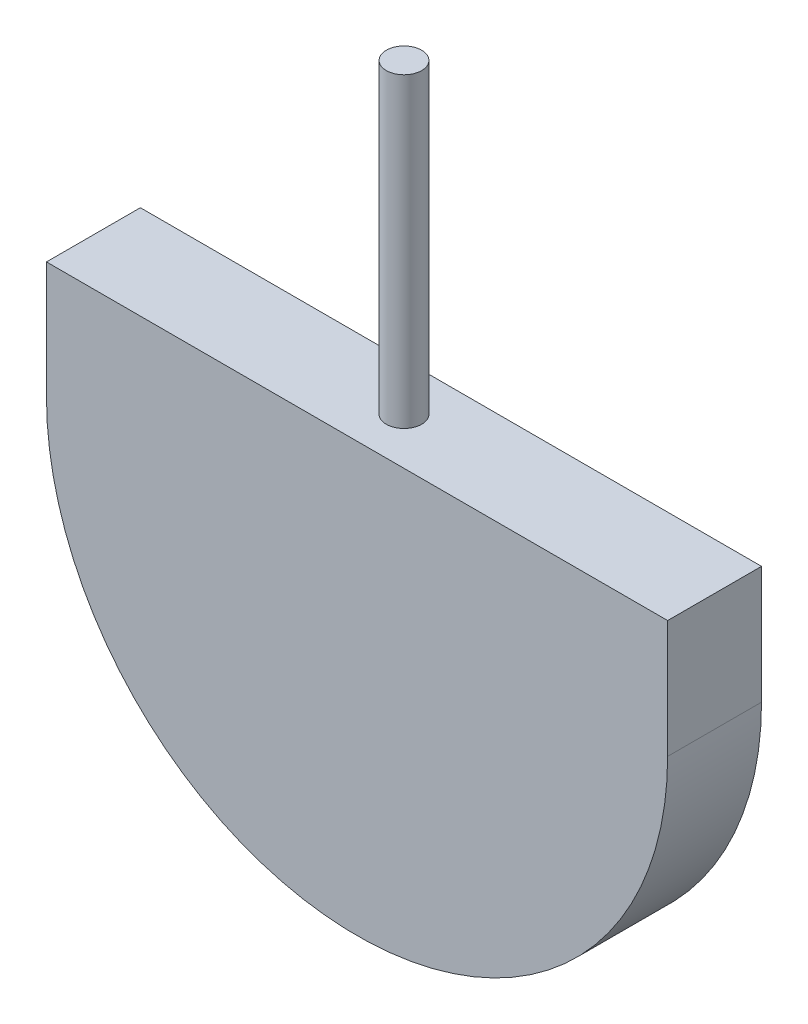
from build123d import *

# Parameters (mm, degrees)
BOSS_EXTRUDE1_DEPTH = 3.99
SKETCH2_R           = 0.75
BOSS_EXTRUDE2_DEPTH = 13.019979


with BuildPart() as part:
    # Sketch1 → Boss-Extrude1 (new body)
    with BuildSketch(Plane.XY):
        with BuildLine():
            Line((-13.2, -2.5), (-13.2, 2.5))
            Line((-13.2, 2.5), (13.2, 2.5))
            Line((13.2, 2.5), (13.2, -2.5))
            ThreePointArc((13.2, -2.5), (0, -15.7), (-13.2, -2.5))
        make_face()
    extrude(amount=BOSS_EXTRUDE1_DEPTH)

    # Sketch2 → Boss-Extrude2 (add)
    with BuildSketch(Plane(origin=(0, 2.5, 0), x_dir=(1, 0, 0), z_dir=(0, 1, 0))):
        with Locations((0, -1.995)):
            Circle(SKETCH2_R)
    extrude(amount=BOSS_EXTRUDE2_DEPTH)


solid = part.part
